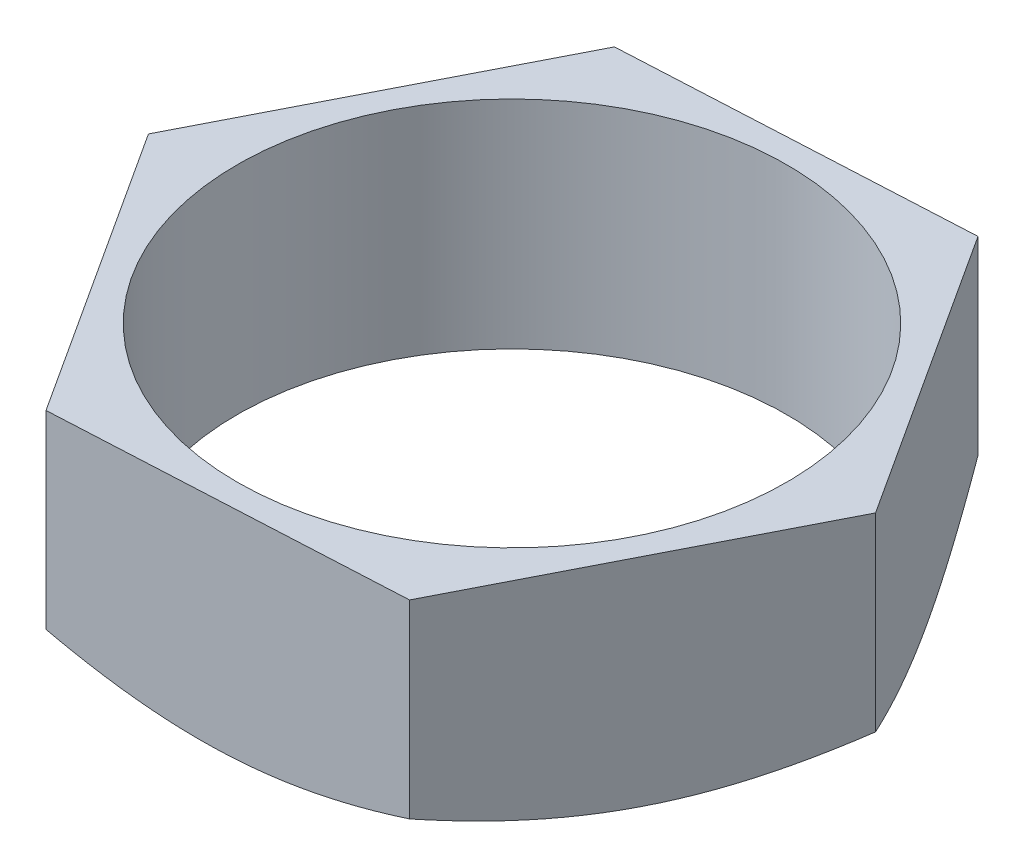
from build123d import *

# Parameters (mm, degrees)
SKETCH4_R           = 6.35
BOSS_EXTRUDE1_DEPTH = 5
SKETCH9_OUTSIDE_W   = 43.162
SKETCH9_OUTSIDE_H   = 41.428
SKETCH9_OUTSIDE_R   = 6.92820323
CUT_EXTRUDE1_DEPTH  = 6
CUT_EXTRUDE1_TAPER  = 60


with BuildPart() as part:
    # Sketch4 → Boss-Extrude1 (new body)
    with BuildSketch(Plane(origin=(0, 0, 0), x_dir=(1, 0, 0), z_dir=(0, 1, 0))):
        Polygon((3.640964438, 7.123438633), (-4.348596599, 6.714887014), (-7.989561038, -0.408551619), (-3.640964438, -7.123438633), (4.348596599, -6.714887014), (7.989561038, 0.408551619), align=None)
        Circle(SKETCH4_R, mode=Mode.SUBTRACT)
    extrude(amount=BOSS_EXTRUDE1_DEPTH)

    # Sketch9 outside → Cut-Extrude1 (cut, through all)
    with BuildSketch(Plane.XZ):
        Rectangle(SKETCH9_OUTSIDE_W, SKETCH9_OUTSIDE_H)
        Circle(SKETCH9_OUTSIDE_R, mode=Mode.SUBTRACT)
    extrude(amount=-CUT_EXTRUDE1_DEPTH, taper=CUT_EXTRUDE1_TAPER, mode=Mode.SUBTRACT)


solid = part.part
